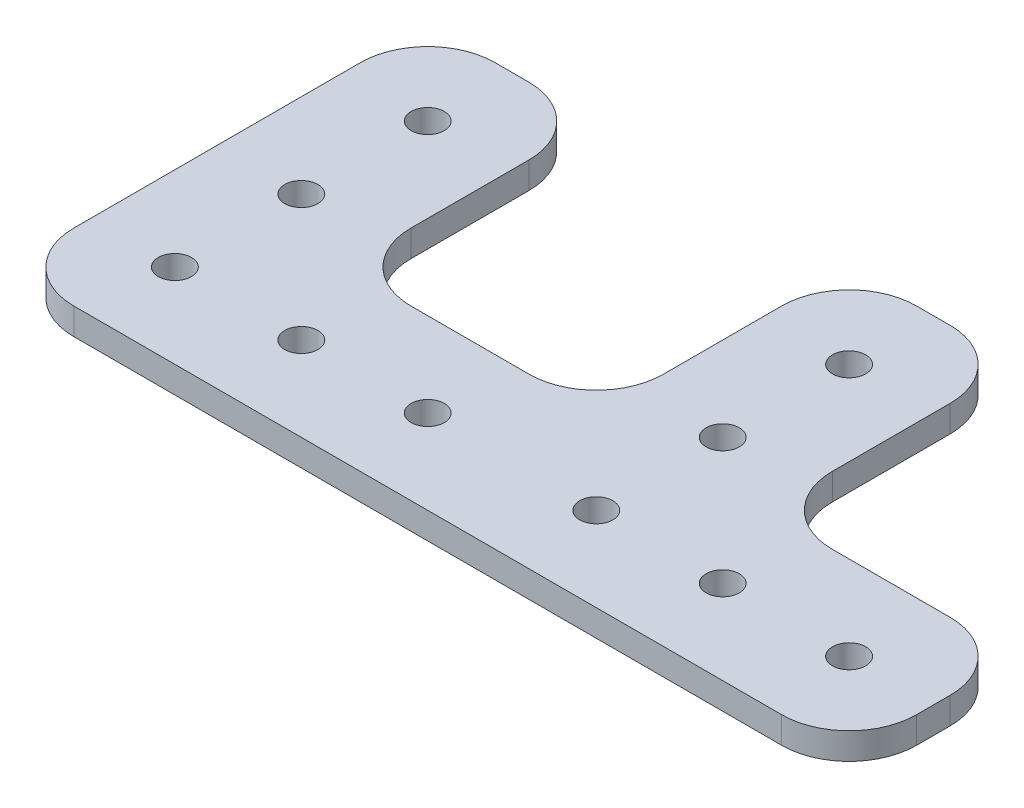
from build123d import *

# Parameters (mm, degrees)
SKETCH1_R           = 2.5
BOSS_EXTRUDE1_DEPTH = 4
FILLET1_R           = 10.16


with BuildPart() as part:
    # Sketch1 → Boss-Extrude1 (new body)
    with BuildSketch(Plane(origin=(0, 25.4, 0), x_dir=(1, 0, 0), z_dir=(0, 1, 0))):
        Polygon((-190.5, -241.3), (-190.5, -279.4), (-190.5, -304.8), (-63.5, -304.8), (-63.5, -279.4), (-101.6, -279.4), (-101.6, -241.3), (-127, -241.3), (-127, -279.4), (-165.1, -279.4), (-165.1, -241.3), align=None)
        with Locations((-114.3, -292.1)):
            Circle(SKETCH1_R, mode=Mode.SUBTRACT)
        with Locations((-177.8, -292.1)):
            Circle(SKETCH1_R, mode=Mode.SUBTRACT)
        with Locations((-158.75, -292.1)):
            Circle(SKETCH1_R, mode=Mode.SUBTRACT)
        with Locations((-95.25, -292.1)):
            Circle(SKETCH1_R, mode=Mode.SUBTRACT)
        with Locations((-139.7, -292.1)):
            Circle(SKETCH1_R, mode=Mode.SUBTRACT)
        with Locations((-76.2, -292.1)):
            Circle(SKETCH1_R, mode=Mode.SUBTRACT)
        with Locations((-114.3, -273.05)):
            Circle(SKETCH1_R, mode=Mode.SUBTRACT)
        with Locations((-177.8, -273.05)):
            Circle(SKETCH1_R, mode=Mode.SUBTRACT)
        with Locations((-114.3, -254)):
            Circle(SKETCH1_R, mode=Mode.SUBTRACT)
        with Locations((-177.8, -254)):
            Circle(SKETCH1_R, mode=Mode.SUBTRACT)
    extrude(amount=BOSS_EXTRUDE1_DEPTH)

    # Fillet1
    fillet1_edges = [part.edges().sort_by_distance(p)[0] for p in [
        (-190.5, 27.4, 304.8),
        (-190.5, 27.4, 241.3),
        (-165.1, 27.4, 241.3),
        (-165.1, 27.4, 279.4),
        (-127, 27.4, 279.4),
        (-127, 27.4, 241.3),
        (-101.6, 27.4, 241.3),
        (-101.6, 27.4, 279.4),
        (-63.5, 27.4, 279.4),
        (-63.5, 27.4, 304.8),
    ]]
    fillet(fillet1_edges, radius=FILLET1_R)


solid = part.part
